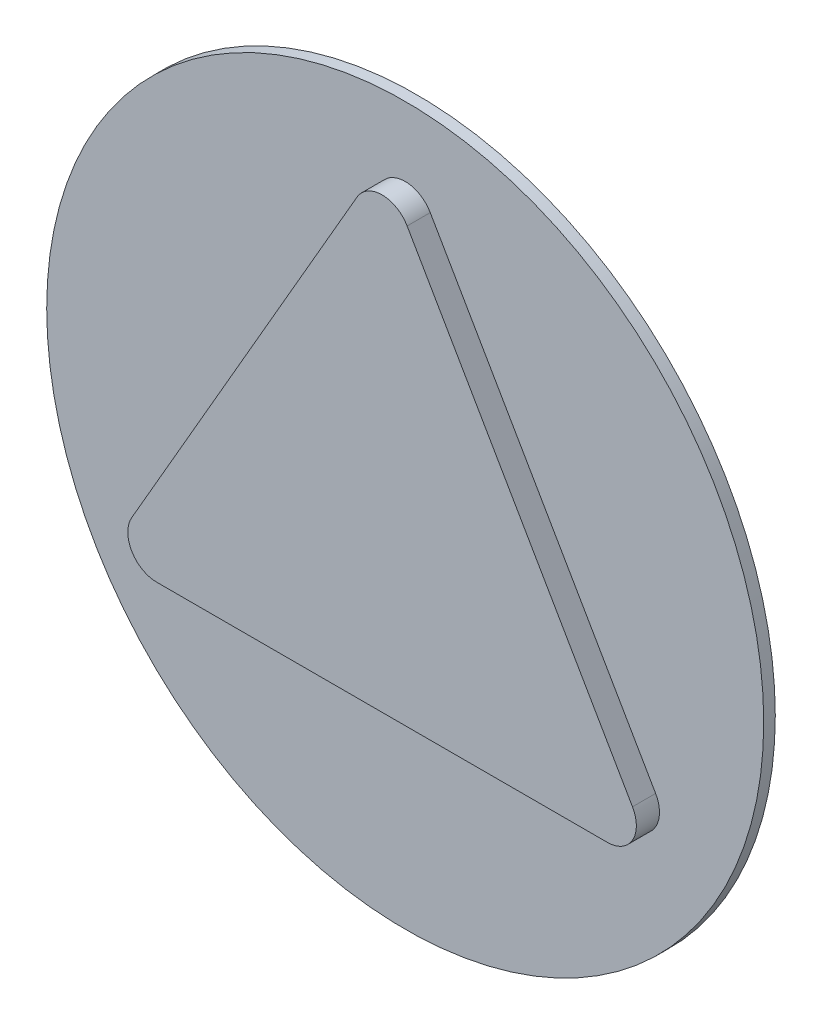
from build123d import *

# Parameters (mm, degrees)
SKETCH1_R           = 15.5
BOSS_EXTRUDE1_DEPTH = 0.5
BOSS_EXTRUDE2_DEPTH = 1
FILLET1_R           = 1.25


with BuildPart() as part:
    # Sketch1 → Boss-Extrude1 (new body)
    with BuildSketch(Plane.XY):
        Circle(SKETCH1_R)
    extrude(amount=BOSS_EXTRUDE1_DEPTH)

    # Sketch2 → Boss-Extrude2 (add)
    with BuildSketch(Plane.XY.offset(0.5)):
        Polygon((-11.907849302, -6.875), (11.907849302, -6.875), (0, 13.75), align=None)
    extrude(amount=BOSS_EXTRUDE2_DEPTH)

    # Fillet1
    fillet1_edges = [part.edges().sort_by_distance(p)[0] for p in [
        (0, 13.75, 1),
        (-11.907849302, -6.875, 1),
        (11.907849302, -6.875, 1),
    ]]
    fillet(fillet1_edges, radius=FILLET1_R)


solid = part.part
